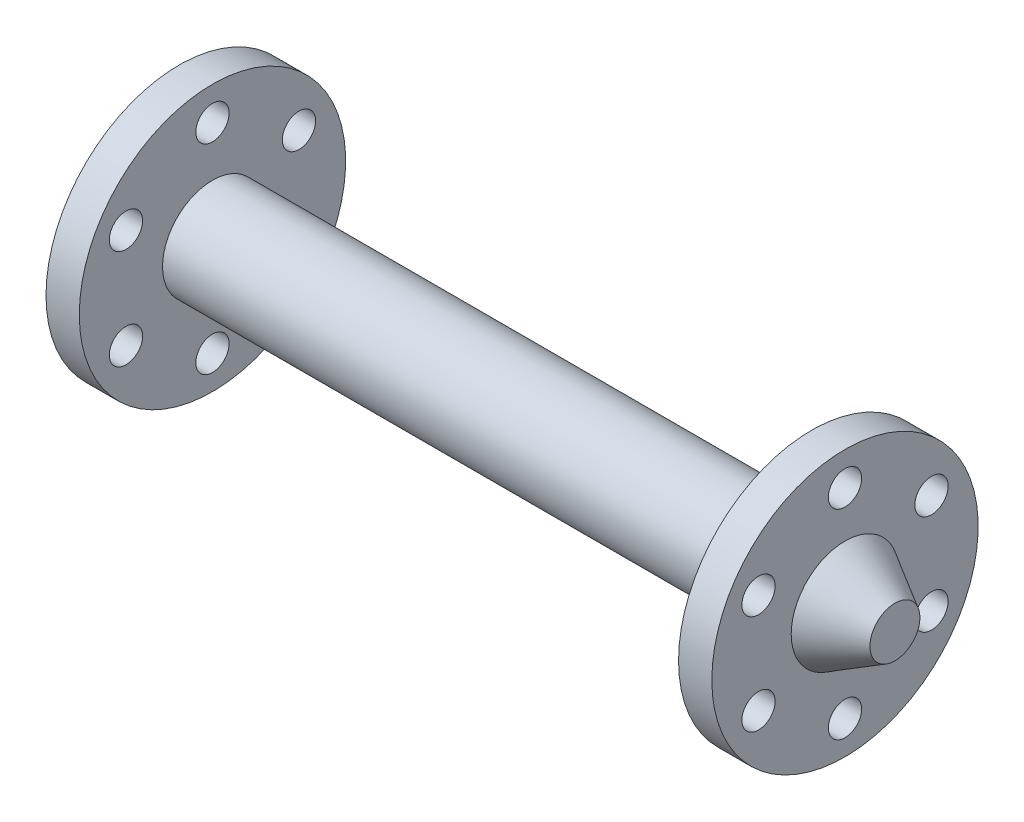
from build123d import *

# Parameters (mm, degrees)
SKETCH3_W               = 360
SKETCH3_H               = 30
SKETCH4_R               = 10
CUT_EXTRUDE1_DEPTH      = 31
CUT_EXTRUDE1_DEPTH_BACK = 431


with BuildPart() as part:
    # Sketch3 → Revolve3 (revolve)
    with BuildSketch(Plane(origin=(0, 0, 0), x_dir=(1, 0, 0), z_dir=(0, 1, 0))):
        Polygon((-10, 32.320508076), (-40, 15), (-40, 0), (-10, 0), align=None)
        Polygon((-10, 80), (-10, 32.320508076), (-10, 0), (10, 0), (10, 30), (10, 80), align=None)
        with Locations((190, 15)):
            Rectangle(SKETCH3_W, SKETCH3_H)
        Polygon((370, 30), (370, 0), (390, 0), (390, 32.320508076), (390, 80), (370, 80), align=None)
        Polygon((390, 32.320508076), (390, 0), (420, 0), (420, 15), align=None)
    revolve(axis=Axis((-40, 0, 0), (1, 0, 0)))

    # Sketch4 → Cut-Extrude1 (cut, two sides)
    with BuildSketch(Plane.ZY.offset(10)) as cut_extrude1_sk:
        with Locations((0, 60)):
            Circle(SKETCH4_R)
        with Locations((51.961524227, 30)):
            Circle(SKETCH4_R)
        with Locations((51.961524227, -30)):
            Circle(SKETCH4_R)
        with Locations((0, -60)):
            Circle(SKETCH4_R)
        with Locations((-51.961524227, -30)):
            Circle(SKETCH4_R)
        with Locations((-51.961524227, 30)):
            Circle(SKETCH4_R)
    extrude(amount=CUT_EXTRUDE1_DEPTH, mode=Mode.SUBTRACT)
    extrude(cut_extrude1_sk.sketch, amount=-CUT_EXTRUDE1_DEPTH_BACK, mode=Mode.SUBTRACT)


solid = part.part
